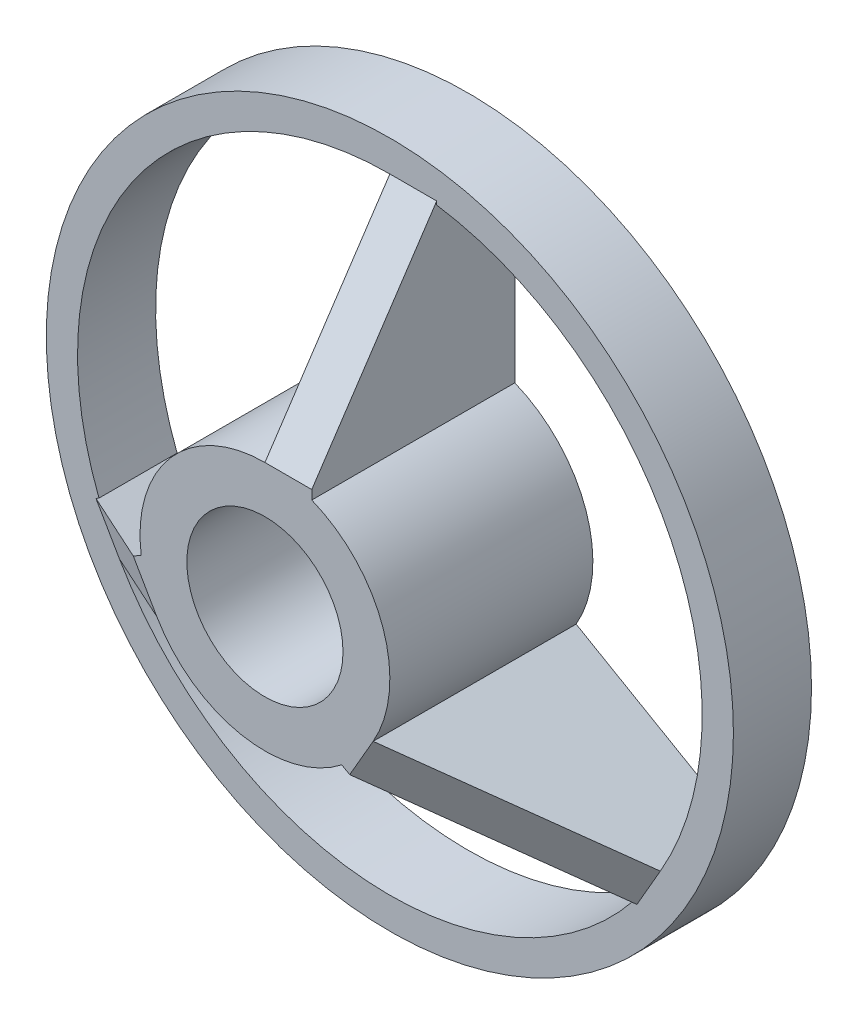
from build123d import *

# Parameters (mm, degrees)
SKETCH7_R            = 22
SKETCH7_R_2          = 20
BOSS_EXTRUDE7_DEPTH  = 5
SKETCH8_R            = 8
SKETCH8_R_2          = 5
BOSS_EXTRUDE8_DEPTH  = 13
BOSS_EXTRUDE10_DEPTH = 3
CIRPATTERN2_COUNT    = 3


with BuildPart() as part:
    # Sketch7 → Boss-Extrude7 (new body)
    with BuildSketch(Plane.XY):
        Circle(SKETCH7_R)
        Circle(SKETCH7_R_2, mode=Mode.SUBTRACT)
    extrude(amount=BOSS_EXTRUDE7_DEPTH)



with BuildPart() as body_2:
    # Sketch8 → Boss-Extrude8 (new body)
    with BuildSketch(Plane.XY):
        Circle(SKETCH8_R)
        Circle(SKETCH8_R_2, mode=Mode.SUBTRACT)
    extrude(amount=BOSS_EXTRUDE8_DEPTH)


with BuildPart() as part_1:
    add(part.part)

    add(body_2.part)  # Boss-Extrude10 merges body 2
    # Sketch9 → Boss-Extrude10 (add)
    with BuildSketch(Plane(origin=(0, 0, 0), x_dir=(0, 0, -1), z_dir=(1, 0, 0))):
        Polygon((-13, 8), (-5, 20), (0, 20), (0, 8), (0, 5), (-13, 5), align=None)
    boss_extrude10 = extrude(amount=BOSS_EXTRUDE10_DEPTH)

    # CirPattern2: Boss-Extrude10 ×3 about axis
    cirpattern2_axis = Axis((0, 0, 0), (0, 0, 1))
    for i in range(1, CIRPATTERN2_COUNT):
        add(boss_extrude10.rotate(cirpattern2_axis, i * 360 / CIRPATTERN2_COUNT))


solid = part_1.part
